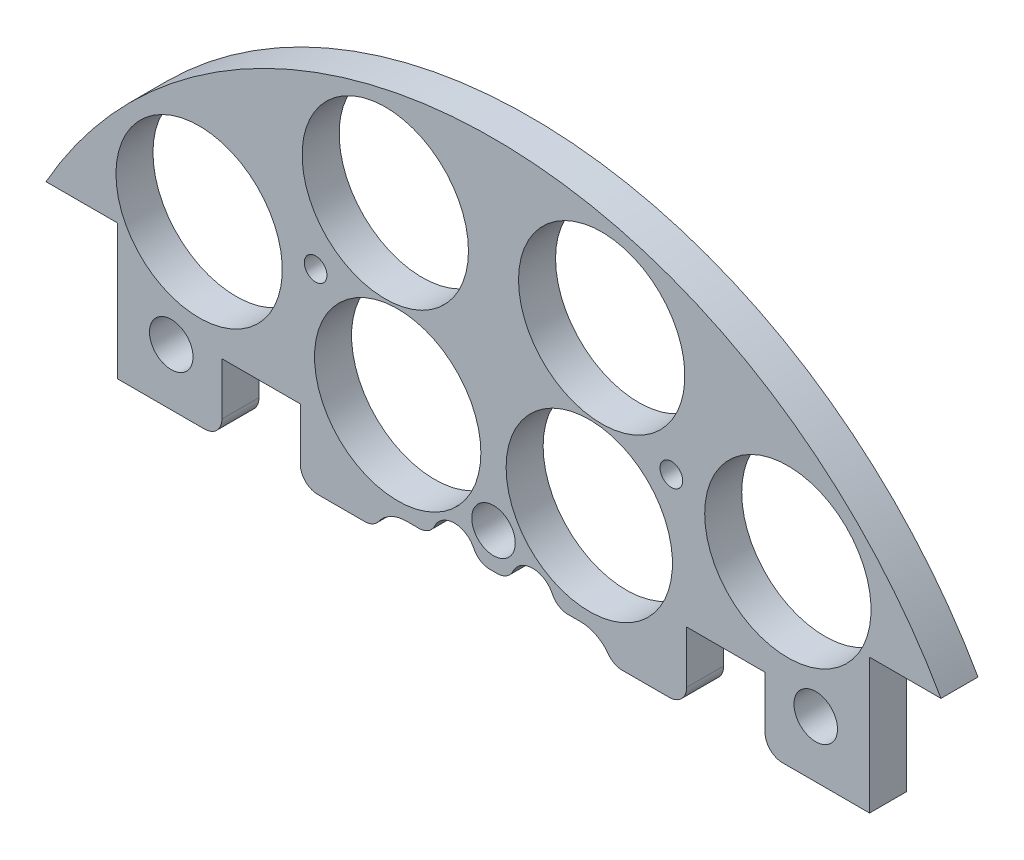
from build123d import *

# Parameters (mm, degrees)
SKETCH1_R                 = 1.651
BOSS_EXTRUDE2_DEPTH       = 5.3975
SKETCH2_R                 = 1.143
CUT_EXTRUDE1_DEPTH        = 6.3975
SKETCH3_R                 = 12.1285
CUT_EXTRUDE2_DEPTH        = 6.3975
SKETCH4_W                 = 28.562713242
SKETCH4_H                 = 11.677503754
BOSS_EXTRUDE3_DEPTH       = 5.3975
SKETCH5_W                 = 230.699333954
SKETCH5_H                 = 107.587024537
CUT_EXTRUDE3_DEPTH        = 6.3975
SKETCH6_R                 = 12.1285
CUT_EXTRUDE4_DEPTH        = 6.3975
SKETCH156_W               = 11.43
SKETCH156_H               = 10.16
CUT_EXTRUDE152_DEPTH      = 6.3975
SKETCH212_R               = 1.651
CUT_EXTRUDE208_DEPTH      = 97.79
SKETCH266_R               = 3.175
CUT_EXTRUDE262_DEPTH      = 103.378
CUT_EXTRUDE262_DEPTH_BACK = 48.768
CUT_EXTRUDE155_DEPTH      = 26.162
FILLET1_R                 = 2.54


with BuildPart() as part:
    # Sketch1 → Boss-Extrude2 (new body)
    with BuildSketch(Plane.XY):
        with BuildLine():
            Line((-65.2537815, 36.83), (-54.8397815, 36.83))
            Line((-54.8397815, 36.83), (-54.8397815, -36.83))
            Line((-54.8397815, -36.83), (-65.2537815, -36.83))
            ThreePointArc((-65.2537815, -36.83), (0, -74.93), (65.2537815, -36.83))
            Line((65.2537815, -36.83), (54.8397815, -36.83))
            Line((54.8397815, -36.83), (54.8397815, 36.83))
            Line((54.8397815, 36.83), (65.2537815, 36.83))
            ThreePointArc((65.2537815, 36.83), (0, 74.93), (-65.2537815, 36.83))
        make_face()
        with Locations((-45.466, 11.049)):
            Circle(SKETCH1_R, mode=Mode.SUBTRACT)
        with Locations((-20.067270032, 10.795)):
            Circle(SKETCH1_R, mode=Mode.SUBTRACT)
        with Locations((-20.067270032, -10.795)):
            Circle(SKETCH1_R, mode=Mode.SUBTRACT)
        with Locations((-45.466, -11.049)):
            Circle(SKETCH1_R, mode=Mode.SUBTRACT)
        with Locations((45.466, -11.049)):
            Circle(SKETCH1_R, mode=Mode.SUBTRACT)
        with Locations((20.067270032, -10.795)):
            Circle(SKETCH1_R, mode=Mode.SUBTRACT)
        with Locations((20.067270032, 10.795)):
            Circle(SKETCH1_R, mode=Mode.SUBTRACT)
        with Locations((45.466, 11.049)):
            Circle(SKETCH1_R, mode=Mode.SUBTRACT)
    extrude(amount=BOSS_EXTRUDE2_DEPTH)

    # Sketch2 → Cut-Extrude1 (cut, through all)
    with BuildSketch(Plane.XY.offset(5.3975)):
        with Locations((-6.731, 62.23)):
            Circle(SKETCH2_R)
        with Locations((6.731, 62.23)):
            Circle(SKETCH2_R)
    extrude(amount=-CUT_EXTRUDE1_DEPTH, mode=Mode.SUBTRACT)

    # Sketch3 → Cut-Extrude2 (cut, through all)
    with BuildSketch(Plane(origin=(0, 0, 0), x_dir=(-1, 0, 0), z_dir=(0, 0, -1))):
        with Locations((-42.926, -42.926)):
            Circle(SKETCH3_R)
        with Locations((13.97, -34.29)):
            Circle(SKETCH3_R)
        with Locations((13.97, 34.29)):
            Circle(SKETCH3_R)
        with Locations((-42.926, 42.926)):
            Circle(SKETCH3_R)
        with Locations((42.926, 42.926)):
            Circle(SKETCH3_R)
        with Locations((-13.97, 34.29)):
            Circle(SKETCH3_R)
        with Locations((-13.97, -34.29)):
            Circle(SKETCH3_R)
        with Locations((42.926, -42.926)):
            Circle(SKETCH3_R)
    extrude(amount=-CUT_EXTRUDE2_DEPTH, mode=Mode.SUBTRACT)

    # Sketch4 → Boss-Extrude3 (add)
    with BuildSketch(Plane(origin=(0, 0, 0), x_dir=(-1, 0, 0), z_dir=(0, 0, -1))):
        with Locations((-1.488809975, 62.152540216)):
            Rectangle(SKETCH4_W, SKETCH4_H)
    extrude(amount=-BOSS_EXTRUDE3_DEPTH)

    # Sketch5 → Cut-Extrude3 (cut, through all)
    with BuildSketch(Plane(origin=(0, 0, 0), x_dir=(-1, 0, 0), z_dir=(0, 0, -1))):
        with Locations((1.971047261, -36.648512269)):
            Rectangle(SKETCH5_W, SKETCH5_H)
    extrude(amount=-CUT_EXTRUDE3_DEPTH, mode=Mode.SUBTRACT)

    # Sketch6 → Cut-Extrude4 (cut, through all)
    with BuildSketch(Plane(origin=(0, 0, 0), x_dir=(-1, 0, 0), z_dir=(0, 0, -1))):
        with Locations((-15.777608989, 58.882838371)):
            Circle(SKETCH6_R)
        with Locations((15.777608989, 58.882838371)):
            Circle(SKETCH6_R)
    extrude(amount=-CUT_EXTRUDE4_DEPTH, mode=Mode.SUBTRACT)

    # Sketch156 → Cut-Extrude152 (cut, through all)
    with BuildSketch(Plane(origin=(0, 0, 0), x_dir=(-1, 0, 0), z_dir=(0, 0, -1))):
        with Locations((33.8847815, 22.225)):
            Rectangle(SKETCH156_W, SKETCH156_H)
        with Locations((-33.8847815, 22.225)):
            Rectangle(SKETCH156_W, SKETCH156_H)
    extrude(amount=-CUT_EXTRUDE152_DEPTH, mode=Mode.SUBTRACT)

    # Sketch212 → Cut-Extrude208 (cut)
    with BuildSketch(Plane(origin=(30.092005081, 4.08352975, -19.2405), x_dir=(-1, 0, 0), z_dir=(0, 0, -1))):
        with Locations((4.154396091, 41.38247025)):
            Circle(SKETCH212_R)
        with Locations((56.02961407, 41.38247025)):
            Circle(SKETCH212_R)
    extrude(amount=-CUT_EXTRUDE208_DEPTH, mode=Mode.SUBTRACT)

    # Sketch266 → Cut-Extrude262 (cut, two sides)
    with BuildSketch(Plane(origin=(30.092005081, 4.08352975, 16.891), x_dir=(-1, 0, 0), z_dir=(0, 0, -1))) as cut_extrude262_sk:
        with Locations((-16.897994919, 21.31647025)):
            Circle(SKETCH266_R)
        with Locations((77.082005081, 21.31647025)):
            Circle(SKETCH266_R)
        with Locations((30.092005081, 21.31647025)):
            Circle(SKETCH266_R)
    extrude(amount=CUT_EXTRUDE262_DEPTH, mode=Mode.SUBTRACT)
    extrude(cut_extrude262_sk.sketch, amount=-CUT_EXTRUDE262_DEPTH_BACK, mode=Mode.SUBTRACT)

    # Sketch159 → Cut-Extrude155 (cut)
    with BuildSketch(Plane(origin=(0, 0, 0), x_dir=(-1, 0, 0), z_dir=(0, 0, -1))):
        with BuildLine():
            Line((12.7, 20.24), (8.888991966, 20.24))
            ThreePointArc((8.888991966, 20.24), (5.715, 23.495), (2.541008034, 20.24))
            Line((2.541008034, 20.24), (-2.541008034, 20.24))
            ThreePointArc((-2.541008034, 20.24), (-5.715, 23.495), (-8.888991966, 20.24))
            Line((-8.888991966, 20.24), (-12.7, 20.24))
            ThreePointArc((-12.7, 20.24), (-16.235533906, 11.704466094), (-7.7, 15.24))
            Line((-7.7, 15.24), (7.7, 15.24))
            ThreePointArc((7.7, 15.24), (16.235533906, 11.704466094), (12.7, 20.24))
        make_face()
    extrude(amount=-CUT_EXTRUDE155_DEPTH, mode=Mode.SUBTRACT)

    # Fillet1
    fillet1_edges = [part.edges().sort_by_distance(p)[0] for p in [
        (-39.5997815, 17.145, 2.69875),
        (-28.1697815, 17.145, 2.69875),
        (28.1697815, 17.145, 2.69875),
        (39.5997815, 17.145, 2.69875),
        (-17.322875188, 17.145, 2.69875),
        (17.322875188, 17.145, 2.69875),
        (8.888991966, 20.24, 2.69875),
        (2.541008034, 20.24, 2.69875),
        (-2.541008034, 20.24, 2.69875),
        (-8.888991966, 20.24, 2.69875),
    ]]
    fillet(fillet1_edges, radius=FILLET1_R)


solid = part.part
